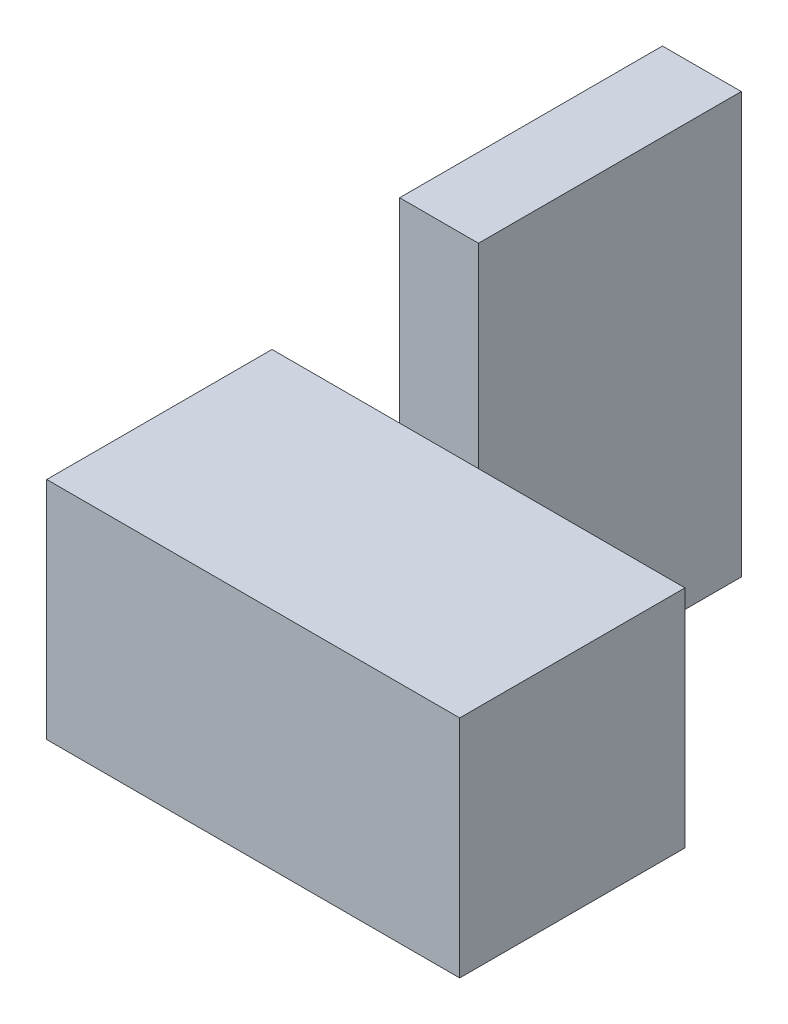
from build123d import *

# Parameters (mm, degrees)
SKETCH1_W           = 55
SKETCH1_H           = 30
BOSS_EXTRUDE1_DEPTH = 30
SKETCH2_W           = 10.5
SKETCH2_H           = 56
BOSS_EXTRUDE2_DEPTH = 35
SKETCH3_W           = 5.5
SKETCH3_H           = 11
CUT_EXTRUDE1_DEPTH  = 22


with BuildPart() as part:
    # Sketch1 → Boss-Extrude1 (new body)
    with BuildSketch(Plane(origin=(0, 0, 0), x_dir=(1, 0, 0), z_dir=(0, 1, 0))):
        Rectangle(SKETCH1_W, SKETCH1_H)
    extrude(amount=BOSS_EXTRUDE1_DEPTH)

    # Sketch2 → Boss-Extrude2 (add)
    with BuildSketch(Plane.XY.offset(15)):
        with Locations((-5.25, 28)):
            Rectangle(SKETCH2_W, SKETCH2_H)
    extrude(amount=BOSS_EXTRUDE2_DEPTH)

    # Sketch3 → Cut-Extrude1 (cut)
    with BuildSketch(Plane.XY.offset(50)):
        with Locations((-5.25, 8.5)):
            Rectangle(SKETCH3_W, SKETCH3_H)
        with Locations((-5.25, 47.5)):
            Rectangle(SKETCH3_W, SKETCH3_H)
    extrude(amount=-CUT_EXTRUDE1_DEPTH, mode=Mode.SUBTRACT)


with BuildPart() as body_2:
    # Mirror1: mirrored copy
    add(part.part.mirror(Plane.XY.offset(50)))


solid = body_2.part
